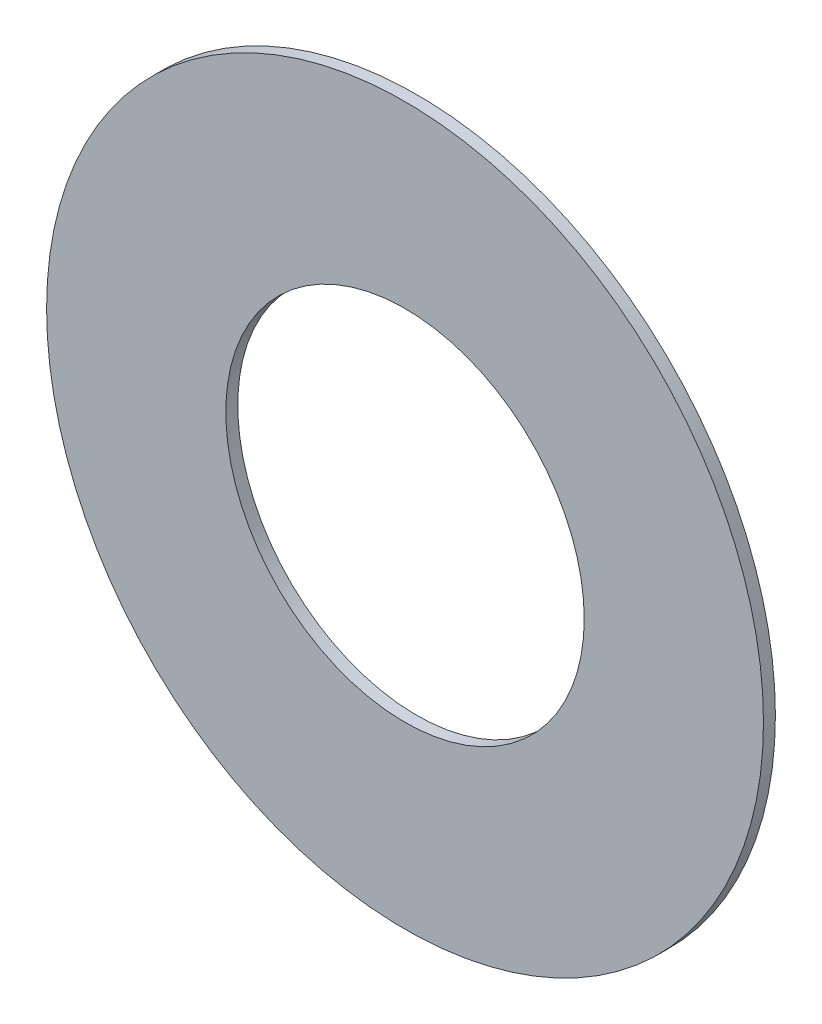
from build123d import *

# Parameters (mm, degrees)
SKETCH1_R           = 3
SKETCH1_R_2         = 1.5
BOSS_EXTRUDE1_DEPTH = 0.1


with BuildPart() as part:
    # Sketch1 → Boss-Extrude1 (new body)
    with BuildSketch(Plane.XY):
        Circle(SKETCH1_R)
        Circle(SKETCH1_R_2, mode=Mode.SUBTRACT)
    extrude(amount=BOSS_EXTRUDE1_DEPTH)


solid = part.part
